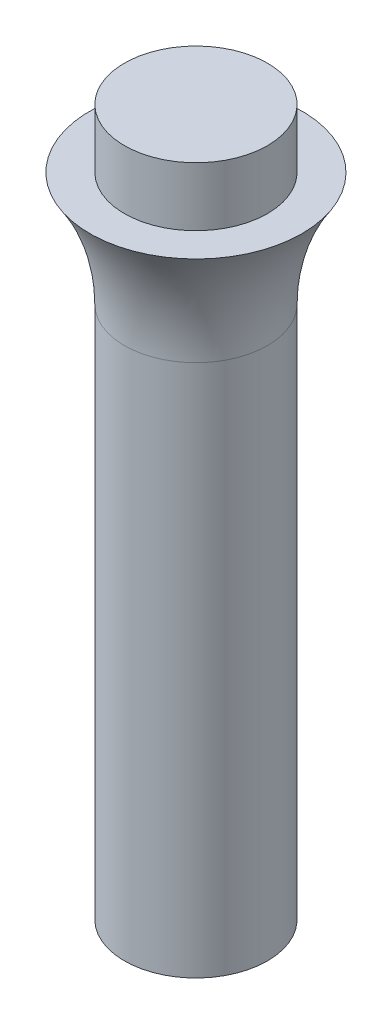
from build123d import *


with BuildPart() as part:
    # Croquis1 → Revolución1 (revolve)
    with BuildSketch(Plane.XY):
        with BuildLine():
            Line((3.828682558, 31.905687985), (0.728682558, 31.905687985))
            Line((0.728682558, 31.905687985), (0.728682558, 15.29733828))
            Line((0.728682558, 15.29733828), (1.978682558, 15.29733828))
            Line((1.978682558, 15.29733828), (1.978682558, 1.29733828))
            Line((1.978682558, 1.29733828), (3.828682558, 1.29733828))
            Line((3.828682558, 1.29733828), (3.828682558, 24.39835879))
            ThreePointArc((3.828682558, 24.39835879), (4.211901933, 26.986832177), (5.328682558, 29.353232947))
            Line((5.328682558, 29.353232947), (3.828682558, 29.353232947))
            Line((3.828682558, 29.353232947), (3.828682558, 31.905687985))
        make_face()
    revolve(axis=Axis((0.728682558, 31.905687985, 0), (0, -1, 0)))


solid = part.part
